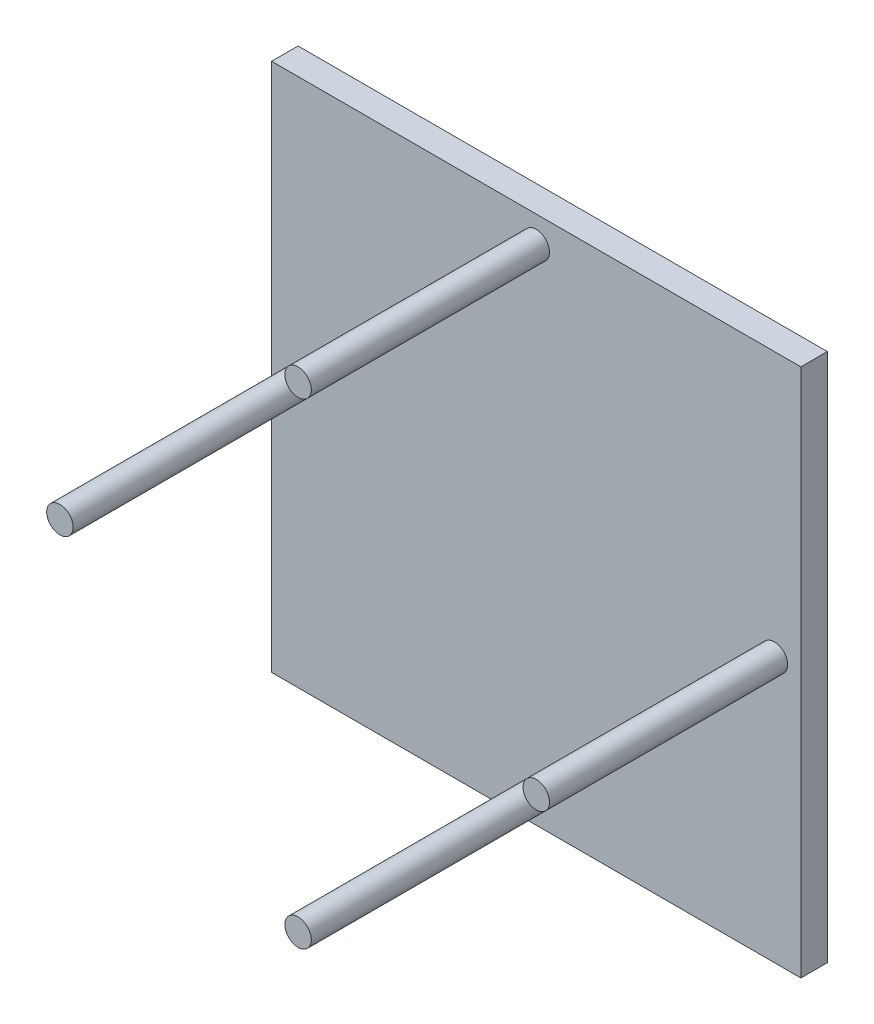
from build123d import *

# Parameters (mm, degrees)
SKETCH1_W           = 200
SKETCH1_H           = 200
BOSS_EXTRUDE1_DEPTH = 10
SKETCH4_R           = 5
BOSS_EXTRUDE2_DEPTH = 100


with BuildPart() as part:
    # Sketch1 → Boss-Extrude1 (new body)
    with BuildSketch(Plane.XY):
        with Locations((100, 100)):
            Rectangle(SKETCH1_W, SKETCH1_H)
    extrude(amount=BOSS_EXTRUDE1_DEPTH)

    # Sketch4 → Boss-Extrude2 (add)
    with BuildSketch(Plane(origin=(0, 0, 0), x_dir=(-1, 0, 0), z_dir=(0, 0, -1))):
        with Locations((-190, 100)):
            Circle(SKETCH4_R)
        with Locations((-100, 10)):
            Circle(SKETCH4_R)
        with Locations((-100, 190)):
            Circle(SKETCH4_R)
        with Locations((-10, 100)):
            Circle(SKETCH4_R)
    extrude(amount=-BOSS_EXTRUDE2_DEPTH)


solid = part.part
